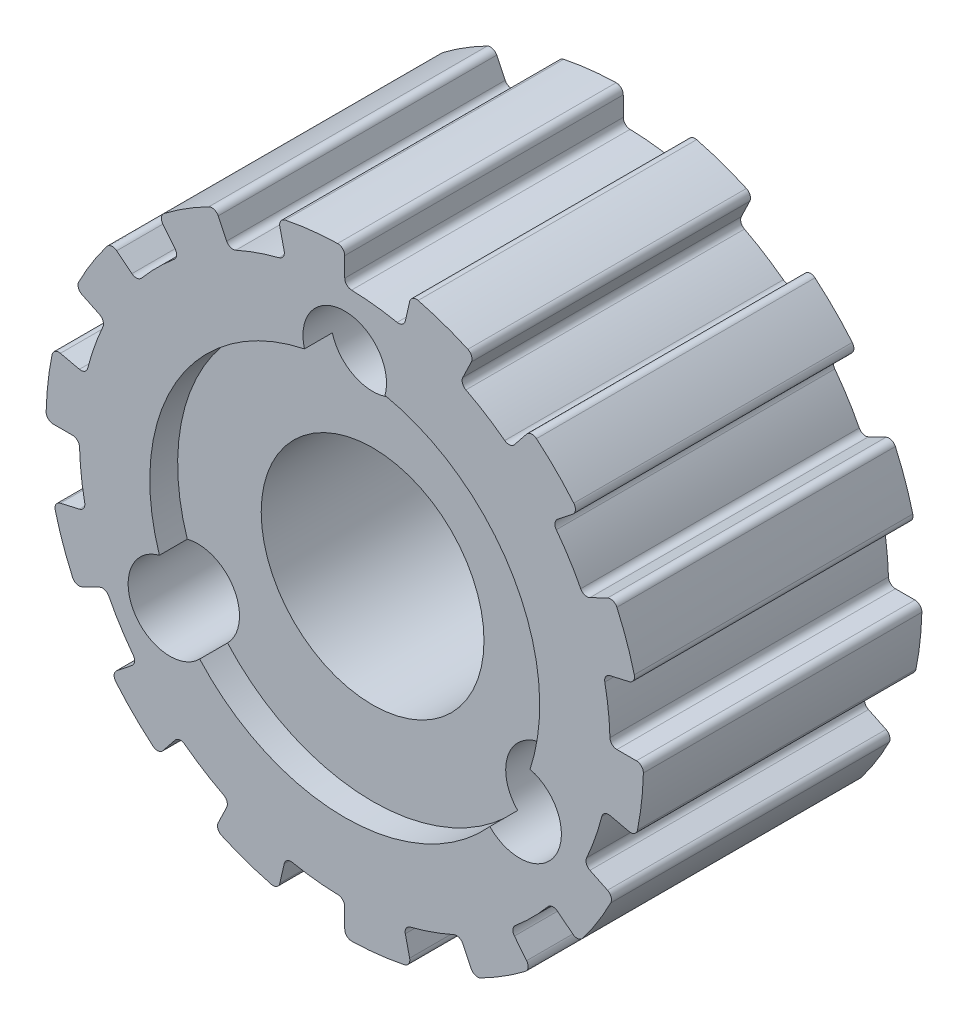
from build123d import *

# Parameters (mm, degrees)
ESQUISSE1_R      = 4
EXTRUSION1_DEPTH = 10
ESQUISSE4_R      = 1.5
EXTRUSION4_DEPTH = 11
ESQUISSE3_R      = 7
EXTRUSION6_DEPTH = 1


with BuildPart() as part:
    # Esquisse1 → Extrusion1 (new body)
    with BuildSketch(Plane.XY):
        with BuildLine():
            Line((4.239826227, 8.804089877), (4.54363758, 9.434960654))
            ThreePointArc((4.54363758, 9.434960654), (4.553364002, 9.628811556), (4.421459692, 9.771198452))
            ThreePointArc((4.421459692, 9.771198452), (3.542242939, 10.123148718), (2.635406201, 10.396165599))
            ThreePointArc((2.635406201, 10.396165599), (2.443502481, 10.367084032), (2.330242843, 10.20946097))
            Line((2.330242843, 10.20946097), (2.174430629, 9.526803055))
            ThreePointArc((2.174430629, 9.526803055), (2.066402933, 9.372470558), (1.881320169, 9.337358268))
            ThreePointArc((1.881320169, 9.337358268), (1.066461635, 9.465108799), (0.243606138, 9.521884322))
            ThreePointArc((0.243606138, 9.521884322), (0.070977005, 9.597301064), (0, 9.771802546))
            Line((0, 9.771802546), (0, 10.472016282))
            ThreePointArc((0, 10.472016282), (-0.075345551, 10.650890045), (-0.255966587, 10.721945071))
            ThreePointArc((-0.255966587, 10.721945071), (-1.200819006, 10.657563451), (-2.136308261, 10.510081447))
            ThreePointArc((-2.136308261, 10.510081447), (-2.29658952, 10.400615957), (-2.330242843, 10.20946097))
            Line((-2.330242843, 10.20946097), (-2.174430629, 9.526803055))
            ThreePointArc((-2.174430629, 9.526803055), (-2.20479786, 9.340882819), (-2.356317016, 9.228943337))
            ThreePointArc((-2.356317016, 9.228943337), (-3.145908065, 8.990488721), (-3.911909227, 8.68461808))
            ThreePointArc((-3.911909227, 8.68461808), (-4.100164799, 8.677665243), (-4.239826227, 8.804089877))
            Line((-4.239826227, 8.804089877), (-4.54363758, 9.434960654))
            ThreePointArc((-4.54363758, 9.434960654), (-4.689131993, 9.563429137), (-4.882695544, 9.549078972))
            ThreePointArc((-4.882695544, 9.549078972), (-5.706044021, 9.081117037), (-6.484900672, 8.542346767))
            ThreePointArc((-6.484900672, 8.542346767), (-6.5818138, 8.374178336), (-6.529195356, 8.187352014))
            Line((-6.529195356, 8.187352014), (-6.092619233, 7.639902871))
            ThreePointArc((-6.092619233, 7.639902871), (-6.039311396, 7.45921868), (-6.127256718, 7.292622993))
            ThreePointArc((-6.127256718, 7.292622993), (-6.735192091, 6.735192091), (-7.292622993, 6.127256718))
            ThreePointArc((-7.292622993, 6.127256718), (-7.45921868, 6.039311396), (-7.639902871, 6.092619233))
            Line((-7.639902871, 6.092619233), (-8.187352014, 6.529195356))
            ThreePointArc((-8.187352014, 6.529195356), (-8.374178336, 6.5818138), (-8.542346767, 6.484900672))
            ThreePointArc((-8.542346767, 6.484900672), (-9.081117037, 5.706044021), (-9.549078972, 4.882695544))
            ThreePointArc((-9.549078972, 4.882695544), (-9.563429137, 4.689131993), (-9.434960654, 4.54363758))
            Line((-9.434960654, 4.54363758), (-8.804089877, 4.239826227))
            ThreePointArc((-8.804089877, 4.239826227), (-8.677665243, 4.100164799), (-8.68461808, 3.911909227))
            ThreePointArc((-8.68461808, 3.911909227), (-8.990488721, 3.145908065), (-9.228943337, 2.356317016))
            ThreePointArc((-9.228943337, 2.356317016), (-9.340882819, 2.20479786), (-9.526803055, 2.174430629))
            Line((-9.526803055, 2.174430629), (-10.20946097, 2.330242843))
            ThreePointArc((-10.20946097, 2.330242843), (-10.400615957, 2.29658952), (-10.510081447, 2.136308261))
            ThreePointArc((-10.510081447, 2.136308261), (-10.657563451, 1.200819006), (-10.721945071, 0.255966587))
            ThreePointArc((-10.721945071, 0.255966587), (-10.650890045, 0.075345551), (-10.472016281, 0))
            Line((-10.472016281, 0), (-9.771802546, 0))
            ThreePointArc((-9.771802546, 0), (-9.597301064, -0.070977005), (-9.521884322, -0.243606138))
            ThreePointArc((-9.521884322, -0.243606138), (-9.465108799, -1.066461635), (-9.337358268, -1.881320169))
            ThreePointArc((-9.337358268, -1.881320169), (-9.372470558, -2.066402933), (-9.526803055, -2.174430629))
            Line((-9.526803055, -2.174430629), (-10.20946097, -2.330242843))
            ThreePointArc((-10.20946097, -2.330242843), (-10.367084032, -2.443502481), (-10.396165599, -2.635406201))
            ThreePointArc((-10.396165599, -2.635406201), (-10.123148718, -3.542242939), (-9.771198452, -4.421459692))
            ThreePointArc((-9.771198452, -4.421459692), (-9.628811556, -4.553364002), (-9.434960654, -4.54363758))
            Line((-9.434960654, -4.54363758), (-8.804089877, -4.239826227))
            ThreePointArc((-8.804089877, -4.239826227), (-8.616073706, -4.228060943), (-8.473224596, -4.35087232))
            ThreePointArc((-8.473224596, -4.35087232), (-8.065047998, -5.067605529), (-7.596394878, -5.746338821))
            ThreePointArc((-7.596394878, -5.746338821), (-7.547725557, -5.928327282), (-7.639902871, -6.092619233))
            Line((-7.639902871, -6.092619233), (-8.187352014, -6.529195356))
            ThreePointArc((-8.187352014, -6.529195356), (-8.280223971, -6.699628848), (-8.223161653, -6.885146144))
            ThreePointArc((-8.223161653, -6.885146144), (-7.583720228, -7.583720228), (-6.885146144, -8.223161653))
            ThreePointArc((-6.885146144, -8.223161653), (-6.699628848, -8.280223971), (-6.529195356, -8.187352014))
            Line((-6.529195356, -8.187352014), (-6.092619233, -7.639902871))
            ThreePointArc((-6.092619233, -7.639902871), (-5.928327282, -7.547725557), (-5.746338821, -7.596394878))
            ThreePointArc((-5.746338821, -7.596394878), (-5.067605529, -8.065047998), (-4.35087232, -8.473224596))
            ThreePointArc((-4.35087232, -8.473224596), (-4.228060943, -8.616073706), (-4.239826227, -8.804089877))
            Line((-4.239826227, -8.804089877), (-4.54363758, -9.434960654))
            ThreePointArc((-4.54363758, -9.434960654), (-4.553364002, -9.628811556), (-4.421459692, -9.771198452))
            ThreePointArc((-4.421459692, -9.771198452), (-3.542242939, -10.123148718), (-2.635406201, -10.396165599))
            ThreePointArc((-2.635406201, -10.396165599), (-2.443502481, -10.367084032), (-2.330242843, -10.20946097))
            Line((-2.330242843, -10.20946097), (-2.174430629, -9.526803055))
            ThreePointArc((-2.174430629, -9.526803055), (-2.066402933, -9.372470558), (-1.881320169, -9.337358268))
            ThreePointArc((-1.881320169, -9.337358268), (-1.066461635, -9.465108799), (-0.243606138, -9.521884322))
            ThreePointArc((-0.243606138, -9.521884322), (-0.070977005, -9.597301064), (0, -9.771802546))
            Line((0, -9.771802546), (0, -10.472016281))
            ThreePointArc((0, -10.472016281), (0.075345551, -10.650890045), (0.255966587, -10.721945071))
            ThreePointArc((0.255966587, -10.721945071), (1.200819006, -10.657563451), (2.136308261, -10.510081447))
            ThreePointArc((2.136308261, -10.510081447), (2.29658952, -10.400615957), (2.330242843, -10.20946097))
            Line((2.330242843, -10.20946097), (2.174430629, -9.526803055))
            ThreePointArc((2.174430629, -9.526803055), (2.20479786, -9.340882819), (2.356317016, -9.228943337))
            ThreePointArc((2.356317016, -9.228943337), (3.145908065, -8.990488721), (3.911909227, -8.68461808))
            ThreePointArc((3.911909227, -8.68461808), (4.100164799, -8.677665243), (4.239826227, -8.804089877))
            Line((4.239826227, -8.804089877), (4.54363758, -9.434960654))
            ThreePointArc((4.54363758, -9.434960654), (4.689131993, -9.563429137), (4.882695544, -9.549078972))
            ThreePointArc((4.882695544, -9.549078972), (5.706044021, -9.081117037), (6.484900672, -8.542346767))
            ThreePointArc((6.484900672, -8.542346767), (6.5818138, -8.374178336), (6.529195356, -8.187352014))
            Line((6.529195356, -8.187352014), (6.092619233, -7.639902871))
            ThreePointArc((6.092619233, -7.639902871), (6.039311396, -7.45921868), (6.127256718, -7.292622993))
            ThreePointArc((6.127256718, -7.292622993), (6.735192091, -6.735192091), (7.292622993, -6.127256718))
            ThreePointArc((7.292622993, -6.127256718), (7.45921868, -6.039311396), (7.639902871, -6.092619233))
            Line((7.639902871, -6.092619233), (8.187352014, -6.529195356))
            ThreePointArc((8.187352014, -6.529195356), (8.374178336, -6.5818138), (8.542346767, -6.484900672))
            ThreePointArc((8.542346767, -6.484900672), (9.081117037, -5.706044021), (9.549078972, -4.882695544))
            ThreePointArc((9.549078972, -4.882695544), (9.563429137, -4.689131993), (9.434960654, -4.54363758))
            Line((9.434960654, -4.54363758), (8.804089877, -4.239826227))
            ThreePointArc((8.804089877, -4.239826227), (8.677665243, -4.100164799), (8.68461808, -3.911909227))
            ThreePointArc((8.68461808, -3.911909227), (8.990488721, -3.145908065), (9.228943337, -2.356317016))
            ThreePointArc((9.228943337, -2.356317016), (9.340882819, -2.20479786), (9.526803055, -2.174430629))
            Line((9.526803055, -2.174430629), (10.20946097, -2.330242843))
            ThreePointArc((10.20946097, -2.330242843), (10.400615957, -2.29658952), (10.510081447, -2.136308261))
            ThreePointArc((10.510081447, -2.136308261), (10.657563451, -1.200819006), (10.721945071, -0.255966587))
            ThreePointArc((10.721945071, -0.255966587), (10.650890045, -0.075345551), (10.472016282, 0))
            Line((10.472016282, 0), (9.771802546, 0))
            ThreePointArc((9.771802546, 0), (9.597301064, 0.070977005), (9.521884322, 0.243606138))
            ThreePointArc((9.521884322, 0.243606138), (9.465108799, 1.066461635), (9.337358268, 1.881320169))
            ThreePointArc((9.337358268, 1.881320169), (9.372470558, 2.066402933), (9.526803055, 2.174430629))
            Line((9.526803055, 2.174430629), (10.20946097, 2.330242843))
            ThreePointArc((10.20946097, 2.330242843), (10.367084032, 2.443502481), (10.396165599, 2.635406201))
            ThreePointArc((10.396165599, 2.635406201), (10.123148718, 3.542242939), (9.771198452, 4.421459692))
            ThreePointArc((9.771198452, 4.421459692), (9.628811556, 4.553364002), (9.434960654, 4.54363758))
            Line((9.434960654, 4.54363758), (8.804089877, 4.239826227))
            ThreePointArc((8.804089877, 4.239826227), (8.616073706, 4.228060943), (8.473224596, 4.35087232))
            ThreePointArc((8.473224596, 4.35087232), (8.065047998, 5.067605529), (7.596394878, 5.746338821))
            ThreePointArc((7.596394878, 5.746338821), (7.547725557, 5.928327282), (7.639902871, 6.092619233))
            Line((7.639902871, 6.092619233), (8.187352014, 6.529195356))
            ThreePointArc((8.187352014, 6.529195356), (8.280223971, 6.699628848), (8.223161653, 6.885146144))
            ThreePointArc((8.223161653, 6.885146144), (7.583720228, 7.583720228), (6.885146144, 8.223161653))
            ThreePointArc((6.885146144, 8.223161653), (6.699628848, 8.280223971), (6.529195356, 8.187352014))
            Line((6.529195356, 8.187352014), (6.092619233, 7.639902871))
            ThreePointArc((6.092619233, 7.639902871), (5.928327282, 7.547725557), (5.746338821, 7.596394878))
            ThreePointArc((5.746338821, 7.596394878), (5.067605529, 8.065047998), (4.35087232, 8.473224596))
            ThreePointArc((4.35087232, 8.473224596), (4.228060943, 8.616073706), (4.239826227, 8.804089877))
        make_face()
        Circle(ESQUISSE1_R, mode=Mode.SUBTRACT)
    extrude(amount=EXTRUSION1_DEPTH)

    # Esquisse4 → Extrusion4 (cut, through all)
    with BuildSketch(Plane(origin=(0, 0, 0), x_dir=(-1, 0, 0), z_dir=(0, 0, -1))):
        with Locations((0, 7.25)):
            Circle(ESQUISSE4_R)
        with Locations((6.278684177, -3.625)):
            Circle(ESQUISSE4_R)
        with Locations((-6.278684177, -3.625)):
            Circle(ESQUISSE4_R)
    extrude(amount=-EXTRUSION4_DEPTH, mode=Mode.SUBTRACT)

    # Esquisse3 → Extrusion6 (cut)
    with BuildSketch(Plane.XY.offset(10)):
        Circle(ESQUISSE3_R)
    extrude(amount=-EXTRUSION6_DEPTH, mode=Mode.SUBTRACT)


solid = part.part
